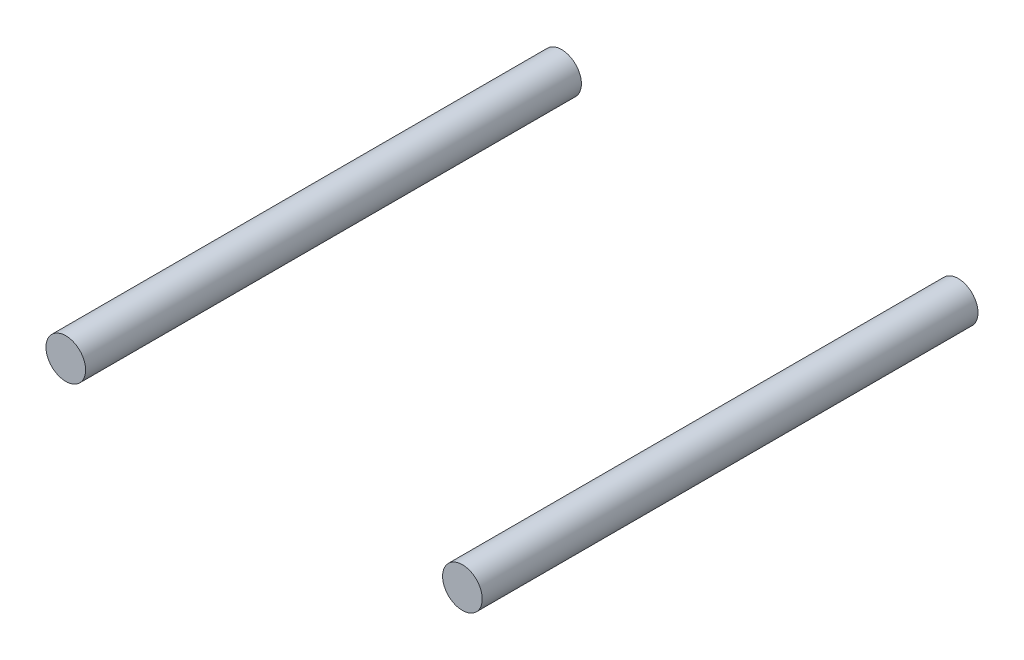
from build123d import *

# Parameters (mm, degrees)
SKETCH1_R             = 0.4
BOSS_EXTRUDE1_DEPTH   = 5
BOSS_EXTRUDE1_2_DEPTH = 5


with BuildPart() as part:
    # Sketch1 → Boss-Extrude1 (new body, symmetric)
    with BuildSketch(Plane.XY):
        with Locations((-4, 0)):
            Circle(SKETCH1_R)
    extrude(amount=BOSS_EXTRUDE1_DEPTH, both=True)


with BuildPart() as body_2:
    # Sketch1 → Boss-Extrude1 2 (new body, symmetric)
    with BuildSketch(Plane.XY):
        with Locations((4, 0)):
            Circle(SKETCH1_R)
    extrude(amount=BOSS_EXTRUDE1_2_DEPTH, both=True)


solid = Compound([part.part, body_2.part])
